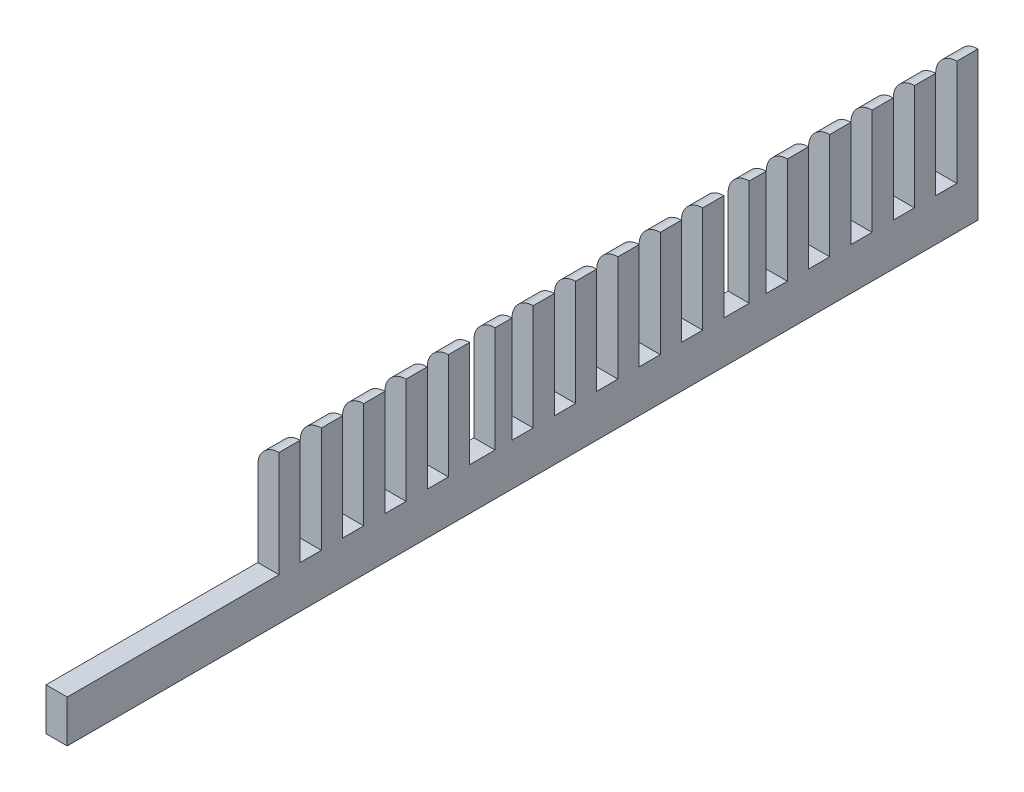
from build123d import *

# Parameters (mm, degrees)
SALIENTE_EXTRUIR1_DEPTH = 85
CROQUIS2_W              = 5
CROQUIS2_H              = 25
CORTAR_EXTRUIR1_DEPTH   = 6
CROQUIS3_W              = 5
CROQUIS3_H              = 10
SALIENTE_EXTRUIR2_DEPTH = 45
CROQUIS4_W              = 1
CROQUIS4_H              = 25
CORTAR_EXTRUIR2_DEPTH   = 6


with BuildPart() as part:
    # Croquis1 → Saliente-Extruir1 (new body, symmetric)
    with BuildSketch(Plane.XY):
        with BuildLine():
            Line((-2.5, -17.5), (2.5, -17.5))
            Line((2.5, -17.5), (2.5, 17.5))
            ThreePointArc((2.5, 17.5), (-1.035533906, 16.035533906), (-2.5, 12.5))
            Line((-2.5, 12.5), (-2.5, -17.5))
        make_face()
    extrude(amount=SALIENTE_EXTRUIR1_DEPTH, both=True)

    # Croquis2 → Cortar-Extruir1 (cut, through all)
    with BuildSketch(Plane(origin=(2.5, 0, 0), x_dir=(0, 0, -1), z_dir=(1, 0, 0))):
        with Locations((77.5, 5)):
            Rectangle(CROQUIS2_W, CROQUIS2_H)
        with Locations((67.5, 5)):
            Rectangle(CROQUIS2_W, CROQUIS2_H)
        with Locations((57.5, 5)):
            Rectangle(CROQUIS2_W, CROQUIS2_H)
        with Locations((47.5, 5)):
            Rectangle(CROQUIS2_W, CROQUIS2_H)
        with Locations((37.5, 5)):
            Rectangle(CROQUIS2_W, CROQUIS2_H)
        with Locations((27.5, 5)):
            Rectangle(CROQUIS2_W, CROQUIS2_H)
        with Locations((17.5, 5)):
            Rectangle(CROQUIS2_W, CROQUIS2_H)
        with Locations((7.5, 5)):
            Rectangle(CROQUIS2_W, CROQUIS2_H)
        with Locations((-2.5, 5)):
            Rectangle(CROQUIS2_W, CROQUIS2_H)
        with Locations((-12.5, 5)):
            Rectangle(CROQUIS2_W, CROQUIS2_H)
        with Locations((-22.5, 5)):
            Rectangle(CROQUIS2_W, CROQUIS2_H)
        with Locations((-32.5, 5)):
            Rectangle(CROQUIS2_W, CROQUIS2_H)
        with Locations((-42.5, 5)):
            Rectangle(CROQUIS2_W, CROQUIS2_H)
        with Locations((-52.5, 5)):
            Rectangle(CROQUIS2_W, CROQUIS2_H)
        with Locations((-62.5, 5)):
            Rectangle(CROQUIS2_W, CROQUIS2_H)
        with Locations((-72.5, 5)):
            Rectangle(CROQUIS2_W, CROQUIS2_H)
        with Locations((-82.5, 5)):
            Rectangle(CROQUIS2_W, CROQUIS2_H)
    extrude(amount=-CORTAR_EXTRUIR1_DEPTH, mode=Mode.SUBTRACT)

    # Croquis3 → Saliente-Extruir2 (add)
    with BuildSketch(Plane.XY.offset(85)):
        with Locations((0, -12.5)):
            Rectangle(CROQUIS3_W, CROQUIS3_H)
    extrude(amount=SALIENTE_EXTRUIR2_DEPTH)

    # Croquis4 → Cortar-Extruir2 (cut, through all)
    with BuildSketch(Plane(origin=(2.5, 0, 0), x_dir=(0, 0, -1), z_dir=(1, 0, 0))):
        with Locations((-29.5, 5)):
            Rectangle(CROQUIS4_W, CROQUIS4_H)
        with Locations((30.5, 5)):
            Rectangle(CROQUIS4_W, CROQUIS4_H)
    extrude(amount=-CORTAR_EXTRUIR2_DEPTH, mode=Mode.SUBTRACT)


solid = part.part
